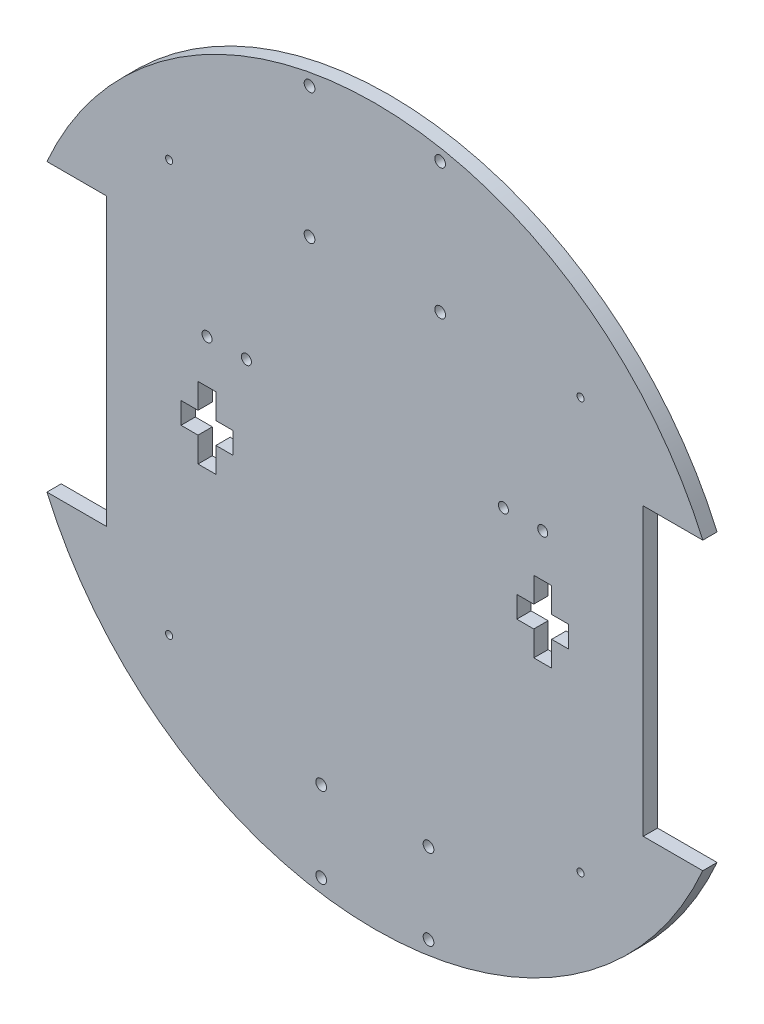
from build123d import *

# Parameters (mm, degrees)
ESBO_O1_R                = 1
ESBO_O1_R_2              = 1.4
ESBO_O1_R_3              = 1.5
RESSALTO_EXTRUS_O2_DEPTH = 4


with BuildPart() as part:
    # Esboço1 → Ressalto-extrusão2 (new body)
    with BuildSketch(Plane.XY):
        with BuildLine():
            Line((75.01453416, -40), (91.651513899, -40))
            ThreePointArc((91.651513899, -40), (0, -100), (-91.651513899, -40))
            Line((-91.651513899, -40), (-74.98546584, -40))
            Line((-74.98546584, -40), (-74.98546584, 40))
            Line((-74.98546584, 40), (-91.651513899, 40))
            ThreePointArc((-91.651513899, 40), (0, 100), (91.651513899, 40))
            Line((91.651513899, 40), (75.01453416, 40))
            Line((75.01453416, 40), (75.01453416, -40))
        make_face()
        with Locations((-57.5, 57.5)):
            Circle(ESBO_O1_R, mode=Mode.SUBTRACT)
        with Locations((57.5, 57.5)):
            Circle(ESBO_O1_R, mode=Mode.SUBTRACT)
        with Locations((57.5, -57.5)):
            Circle(ESBO_O1_R, mode=Mode.SUBTRACT)
        with Locations((-57.5, -57.5)):
            Circle(ESBO_O1_R, mode=Mode.SUBTRACT)
        with Locations((-46.9, 20)):
            Circle(ESBO_O1_R_2, mode=Mode.SUBTRACT)
        with Locations((46.92453416, 19.902879261)):
            Circle(ESBO_O1_R_2, mode=Mode.SUBTRACT)
        with Locations((-18.25, 95)):
            Circle(ESBO_O1_R_3, mode=Mode.SUBTRACT)
        with Locations((18.25, 95)):
            Circle(ESBO_O1_R_3, mode=Mode.SUBTRACT)
        with Locations((18.25, 58.5)):
            Circle(ESBO_O1_R_3, mode=Mode.SUBTRACT)
        with Locations((-18.25, 58.5)):
            Circle(ESBO_O1_R_3, mode=Mode.SUBTRACT)
        with Locations((-15, -95)):
            Circle(ESBO_O1_R_3, mode=Mode.SUBTRACT)
        with Locations((15, -95)):
            Circle(ESBO_O1_R_3, mode=Mode.SUBTRACT)
        with Locations((15, -72.5)):
            Circle(ESBO_O1_R_3, mode=Mode.SUBTRACT)
        with Locations((-15, -72.5)):
            Circle(ESBO_O1_R_3, mode=Mode.SUBTRACT)
        with Locations((-35.9, 20)):
            Circle(ESBO_O1_R_2, mode=Mode.SUBTRACT)
        with Locations((35.92453416, 20)):
            Circle(ESBO_O1_R_2, mode=Mode.SUBTRACT)
        Polygon((49.42453416, -5.097120739), (49.42453416, -12.097120739), (44.42453416, -12.097120739), (44.42453416, -5.097120739), (39.67453416, -5.097120739), (39.67453416, 0.902879261), (44.42453416, 0.902879261), (44.42453416, 7.902879261), (49.42453416, 7.902879261), (49.42453416, 0.902879261), (54.17453416, 0.902879261), (54.17453416, -5.097120739), align=None, mode=Mode.SUBTRACT)
        Polygon((-54.17453416, 0.902879261), (-54.17453416, -5.097120739), (-49.42453416, -5.097120739), (-49.42453416, -12.097120739), (-44.42453416, -12.097120739), (-44.42453416, -5.097120739), (-39.67453416, -5.097120739), (-39.67453416, 0.902879261), (-44.42453416, 0.902879261), (-44.42453416, 7.902879261), (-49.42453416, 7.902879261), (-49.42453416, 0.902879261), align=None, mode=Mode.SUBTRACT)
    extrude(amount=RESSALTO_EXTRUS_O2_DEPTH)


solid = part.part
